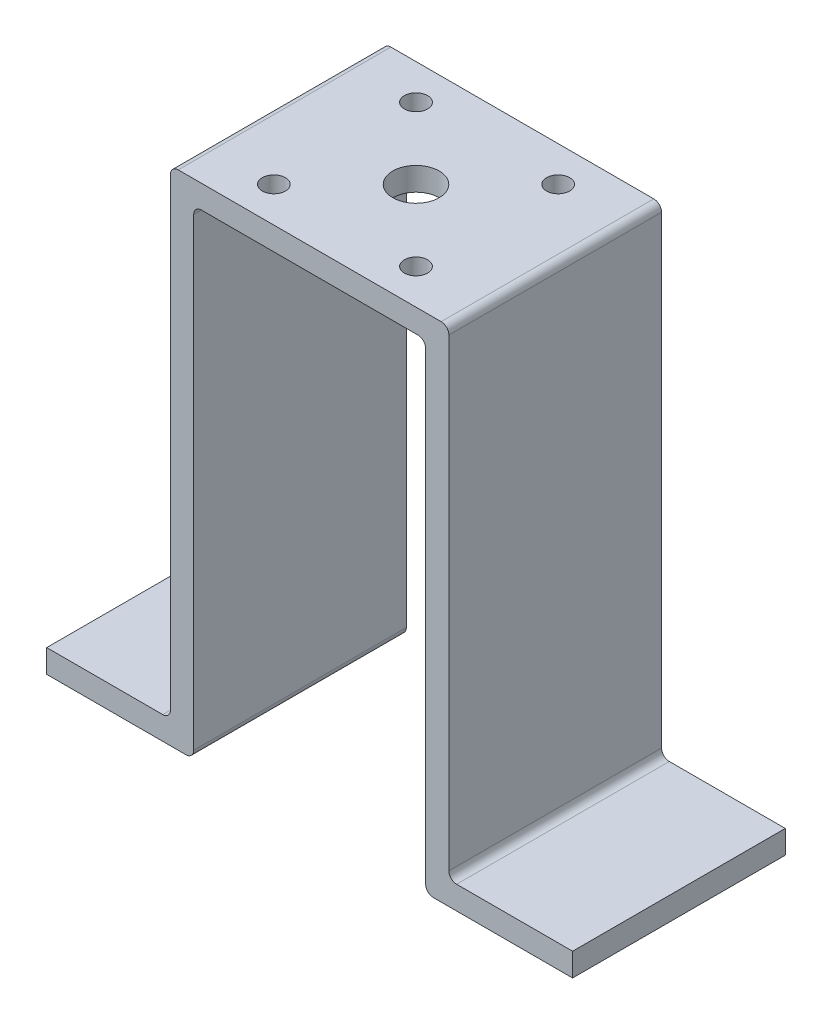
from build123d import *

# Parameters (mm, degrees)
BOSS_EXTRUDE1_DEPTH = 13.75
SKETCH2_R           = 3
SKETCH2_R_2         = 1.5
CUT_EXTRUDE1_DEPTH  = 66


with BuildPart() as part:
    # Sketch1 → Boss-Extrude1 (new body, symmetric)
    with BuildSketch(Plane.XY):
        with BuildLine():
            Line((0, 37.295033495), (-14, 37.295033495))
            ThreePointArc((-14, 37.295033495), (-14.707106781, 37.002140277), (-15, 36.295033495))
            Line((-15, 36.295033495), (-15, -23.704966505))
            ThreePointArc((-15, -23.704966505), (-15.292893219, -24.412073286), (-16, -24.704966505))
            Line((-16, -24.704966505), (-34, -24.704966505))
            Line((-34, -24.704966505), (-34, -21.704966505))
            Line((-34, -21.704966505), (-19, -21.704966505))
            ThreePointArc((-19, -21.704966505), (-18.292893219, -21.412073286), (-18, -20.704966505))
            Line((-18, -20.704966505), (-18, 39.295033495))
            ThreePointArc((-18, 39.295033495), (-17.707106781, 40.002140277), (-17, 40.295033495))
            Line((-17, 40.295033495), (0, 40.295033495))
            Line((0, 40.295033495), (0, 37.295033495))
        make_face()
    boss_extrude1 = extrude(amount=BOSS_EXTRUDE1_DEPTH, both=True)

    # Mirror1: Boss-Extrude1 across plane
    add(boss_extrude1.mirror(Plane(origin=(0, 0, 0), x_dir=(0, 0, 1), z_dir=(1, 0, 0))))

    # Sketch2 → Cut-Extrude1 (cut, through all)
    with BuildSketch(Plane(origin=(0, 40.295033495, 0), x_dir=(1, 0, 0), z_dir=(0, 1, 0))):
        Circle(SKETCH2_R)
        with Locations((-9.19, 9.19)):
            Circle(SKETCH2_R_2)
        with Locations((9.19, 9.19)):
            Circle(SKETCH2_R_2)
        with Locations((9.19, -9.19)):
            Circle(SKETCH2_R_2)
        with Locations((-9.19, -9.19)):
            Circle(SKETCH2_R_2)
    extrude(amount=-CUT_EXTRUDE1_DEPTH, mode=Mode.SUBTRACT)


solid = part.part
